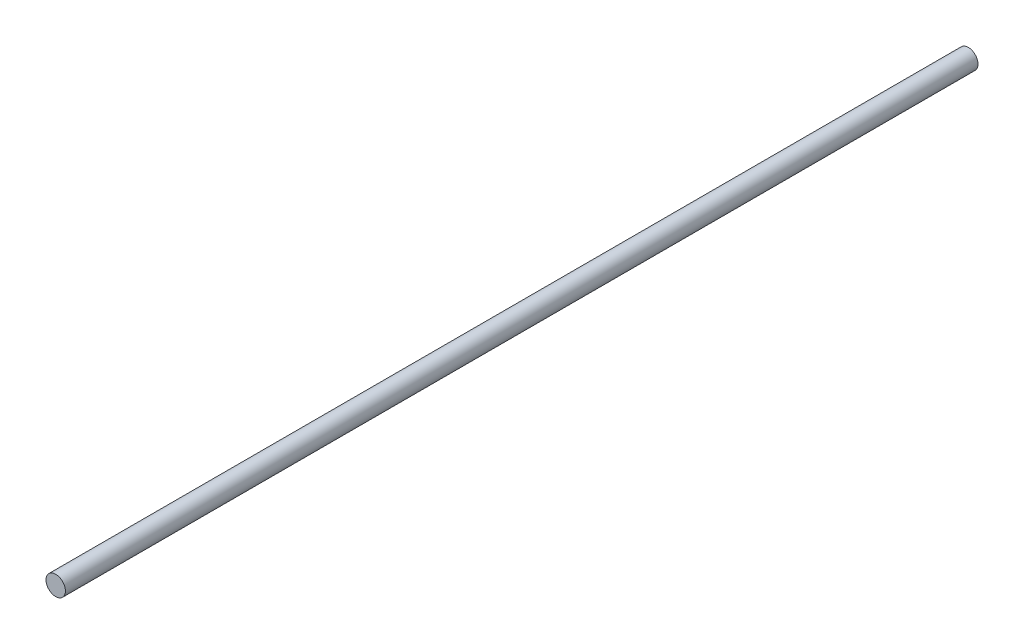
from build123d import *

# Parameters (mm, degrees)
SKETCH1_R           = 2.5
BOSS_EXTRUDE1_DEPTH = 117.5


with BuildPart() as part:
    # Sketch1 → Boss-Extrude1 (new body, symmetric)
    with BuildSketch(Plane.XY):
        Circle(SKETCH1_R)
    extrude(amount=BOSS_EXTRUDE1_DEPTH, both=True)


solid = part.part
